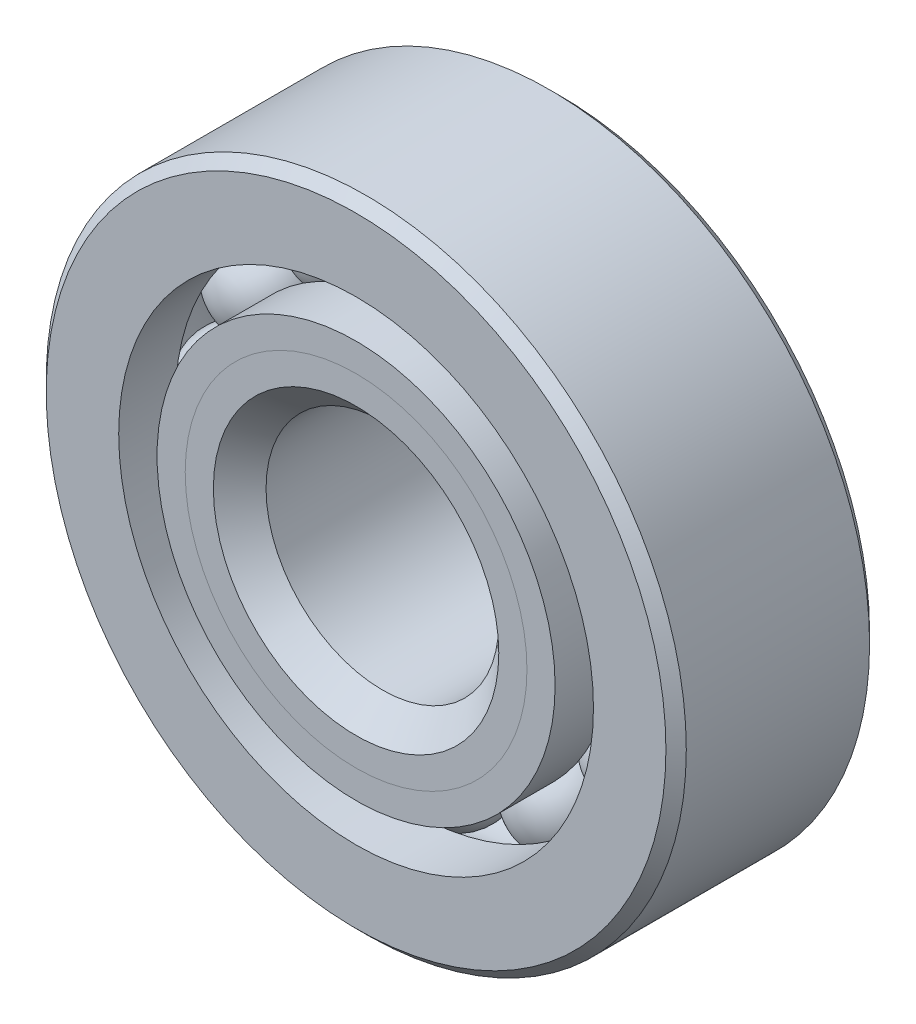
from build123d import *

# Parameters (mm, degrees)
CIRPATTERN1_COUNT = 12


with BuildPart() as part:
    # Sketch1 → Revolve1 (revolve)
    with BuildSketch(Plane(origin=(0, 0, 0), x_dir=(0, 0, -1), z_dir=(1, 0, 0)), mode=Mode.PRIVATE) as revolve1_sk:
        with BuildLine():
            Line((5.000625, 17.4625), (-5.000625, 17.4625))
            Line((-5.000625, 17.4625), (-5.55625, 16.906875))
            Line((-5.55625, 16.906875), (-5.55625, 12.952953297))
            Line((-5.55625, 12.952953297), (-2.469444444, 12.952953297))
            ThreePointArc((-2.469444444, 12.952953297), (0, 14.588365519), (2.469444444, 12.952953297))
            Line((2.469444444, 12.952953297), (5.55625, 12.952953297))
            Line((5.55625, 12.952953297), (5.55625, 16.906875))
            Line((5.55625, 16.906875), (5.000625, 17.4625))
        make_face()
    revolve(revolve1_sk.sketch.rotate(Axis((0, 0, 5.55625), (0, 0, -1)), 90), axis=Axis((0, 0, 5.55625), (0, 0, -1)))  # turned: the seam where the file's is


with BuildPart() as body_2:
    # Sketch2 → Revolve2 (revolve)
    with BuildSketch(Plane(origin=(0, 0, 0), x_dir=(0, 0, -1), z_dir=(1, 0, 0)), mode=Mode.PRIVATE) as revolve2_sk:
        with BuildLine():
            Line((-5.55625, 10.859546703), (-2.469444444, 10.859546703))
            ThreePointArc((-2.469444444, 10.859546703), (-1.480939651, 9.670056492), (0, 9.224134481))
            Line((0, 9.224134481), (0, 7.787067241))
            Line((0, 7.787067241), (-4.020010269, 7.787067241))
            Line((-4.020010269, 7.787067241), (-5.55625, 9.323306972))
            Line((-5.55625, 9.323306972), (-5.55625, 10.859546703))
        make_face()
    revolve(revolve2_sk.sketch.rotate(Axis((0, 0, 5.55625), (0, 0, -1)), 90), axis=Axis((0, 0, 5.55625), (0, 0, -1)))  # turned: the seam where the file's is


with BuildPart() as body_3:
    # Sketch3 → Revolve3 (revolve)
    with BuildSketch(Plane(origin=(0, 0, 0), x_dir=(0, 0, -1), z_dir=(1, 0, 0)), mode=Mode.PRIVATE) as revolve3_sk:
        with BuildLine():
            Line((-5.55625, 9.323306972), (-4.020010269, 7.787067241))
            Line((-4.020010269, 7.787067241), (0, 7.787067241))
            Line((0, 7.787067241), (0, 9.224134481))
            ThreePointArc((0, 9.224134481), (1.480939651, 9.670056492), (2.469444444, 10.859546703))
            Line((2.469444444, 10.859546703), (5.55625, 10.859546703))
            Line((5.55625, 10.859546703), (5.55625, 6.905625))
            Line((5.55625, 6.905625), (5.000625, 6.35))
            Line((5.000625, 6.35), (-4.119182759, 6.35))
            Line((-4.119182759, 6.35), (-5.55625, 7.787067241))
            Line((-5.55625, 7.787067241), (-5.55625, 9.323306972))
        make_face()
    revolve(revolve3_sk.sketch.rotate(Axis((0, 0, 5.55625), (0, 0, -1)), 90), axis=Axis((0, 0, 5.55625), (0, 0, -1)))  # turned: the seam where the file's is


with BuildPart() as body_4:
    # Sketch4 → Revolve4 (revolve)
    with BuildSketch(Plane(origin=(0, 0, 0), x_dir=(0, 0, -1), z_dir=(1, 0, 0))):
        with BuildLine():
            Line((-2.682115519, 11.90625), (2.682115519, 11.90625))
            ThreePointArc((2.682115519, 11.90625), (0, 14.588365519), (-2.682115519, 11.90625))
        make_face()
    revolve(axis=Axis((0, 11.90625, 2.682115519), (0, 0, -1)))


with BuildPart() as cirpattern1_1:
    # CirPattern1: pattern copy
    add(body_4.part.rotate(Axis((0, 0, 0), (0, 0, 1)), 1 * 360 / CIRPATTERN1_COUNT))


with BuildPart() as cirpattern1_2:
    # CirPattern1: pattern copy
    add(body_4.part.rotate(Axis((0, 0, 0), (0, 0, 1)), 2 * 360 / CIRPATTERN1_COUNT))


with BuildPart() as cirpattern1_3:
    # CirPattern1: pattern copy
    add(body_4.part.rotate(Axis((0, 0, 0), (0, 0, 1)), 3 * 360 / CIRPATTERN1_COUNT))


with BuildPart() as cirpattern1_4:
    # CirPattern1: pattern copy
    add(body_4.part.rotate(Axis((0, 0, 0), (0, 0, 1)), 4 * 360 / CIRPATTERN1_COUNT))


with BuildPart() as cirpattern1_5:
    # CirPattern1: pattern copy
    add(body_4.part.rotate(Axis((0, 0, 0), (0, 0, 1)), 5 * 360 / CIRPATTERN1_COUNT))


with BuildPart() as cirpattern1_6:
    # CirPattern1: pattern copy
    add(body_4.part.rotate(Axis((0, 0, 0), (0, 0, 1)), 6 * 360 / CIRPATTERN1_COUNT))


with BuildPart() as cirpattern1_7:
    # CirPattern1: pattern copy
    add(body_4.part.rotate(Axis((0, 0, 0), (0, 0, 1)), 7 * 360 / CIRPATTERN1_COUNT))


with BuildPart() as cirpattern1_8:
    # CirPattern1: pattern copy
    add(body_4.part.rotate(Axis((0, 0, 0), (0, 0, 1)), 8 * 360 / CIRPATTERN1_COUNT))


with BuildPart() as cirpattern1_9:
    # CirPattern1: pattern copy
    add(body_4.part.rotate(Axis((0, 0, 0), (0, 0, 1)), 9 * 360 / CIRPATTERN1_COUNT))


with BuildPart() as cirpattern1_10:
    # CirPattern1: pattern copy
    add(body_4.part.rotate(Axis((0, 0, 0), (0, 0, 1)), 10 * 360 / CIRPATTERN1_COUNT))


with BuildPart() as cirpattern1_11:
    # CirPattern1: pattern copy
    add(body_4.part.rotate(Axis((0, 0, 0), (0, 0, 1)), 11 * 360 / CIRPATTERN1_COUNT))


solid = Compound([part.part, body_2.part, body_3.part, body_4.part, cirpattern1_1.part, cirpattern1_2.part, cirpattern1_3.part, cirpattern1_4.part, cirpattern1_5.part, cirpattern1_6.part, cirpattern1_7.part, cirpattern1_8.part, cirpattern1_9.part, cirpattern1_10.part, cirpattern1_11.part])
